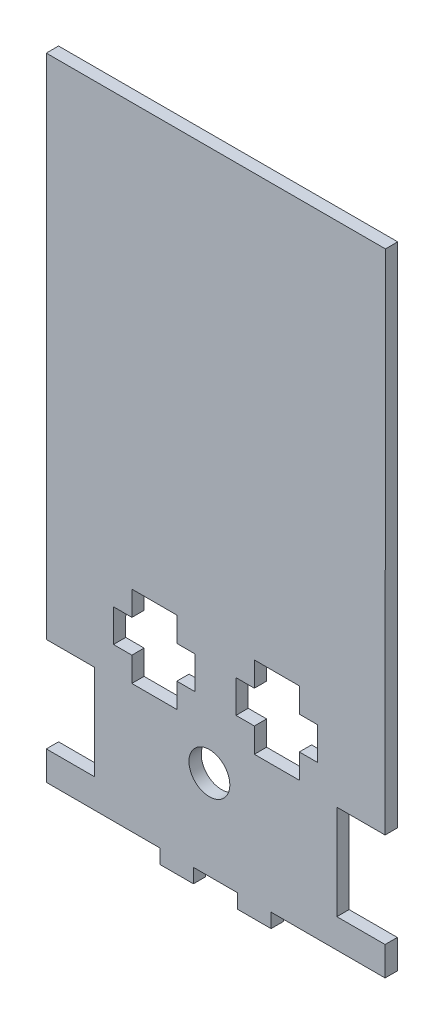
from build123d import *

# Parameters (mm, degrees)
MODEL_R                 = 5
SALIENTE_EXTRUIR1_DEPTH = 3


with BuildPart() as part:
    # Model → Saliente-Extruir1 (new body)
    with BuildSketch(Plane.XY):
        Polygon((4.111589817, 100.015674998), (4.111565333, -10.669034302), (4.111569102, -24.246637901), (15.911569751, -24.246637901), (15.911569751, -47.446638901), (4.111568751, -47.446638901), (4.111568751, -54.531377488), (31.918927332, -54.54545045), (31.918927332, -58.038983798), (40.118927332, -58.038983798), (40.118927332, -54.538983798), (50.918927332, -54.538983798), (50.918927332, -58.038983798), (59.118927332, -58.038983798), (59.118927332, -54.538983798), (87.018940879, -54.546637), (87.018940879, -47.446639), (75.218940879, -47.446639), (75.218940879, -24.246638), (87.018940879, -24.246638), (87.111592427, 100.015659295), align=None)
        with Locations((44.026491998, -32.632550575)):
            Circle(MODEL_R, mode=Mode.SUBTRACT)
        Polygon((25.045319697, -23.106306752), (25.052514337, -17.106311065), (20.552517572, -17.100915085), (20.562110425, -9.100920836), (25.06210719, -9.106316817), (25.06930183, -3.10632113), (36.069293922, -3.119511304), (36.062099282, -9.11950699), (40.562096047, -9.12490297), (40.552503193, -17.124897219), (36.052506429, -17.119501239), (36.045311789, -23.119496925), align=None, mode=Mode.SUBTRACT)
        Polygon((66.030211381, -23.130879389), (66.030211381, -17.130879389), (70.530211381, -17.130879389), (70.530211381, -9.130879389), (66.030211381, -9.130879389), (66.030211381, -3.130879389), (55.030211381, -3.130879389), (55.030211381, -9.130879389), (50.530211381, -9.130879389), (50.530211381, -17.130879389), (55.030211381, -17.130879389), (55.030211381, -23.130879389), align=None, mode=Mode.SUBTRACT)
    extrude(amount=SALIENTE_EXTRUIR1_DEPTH)


solid = part.part
